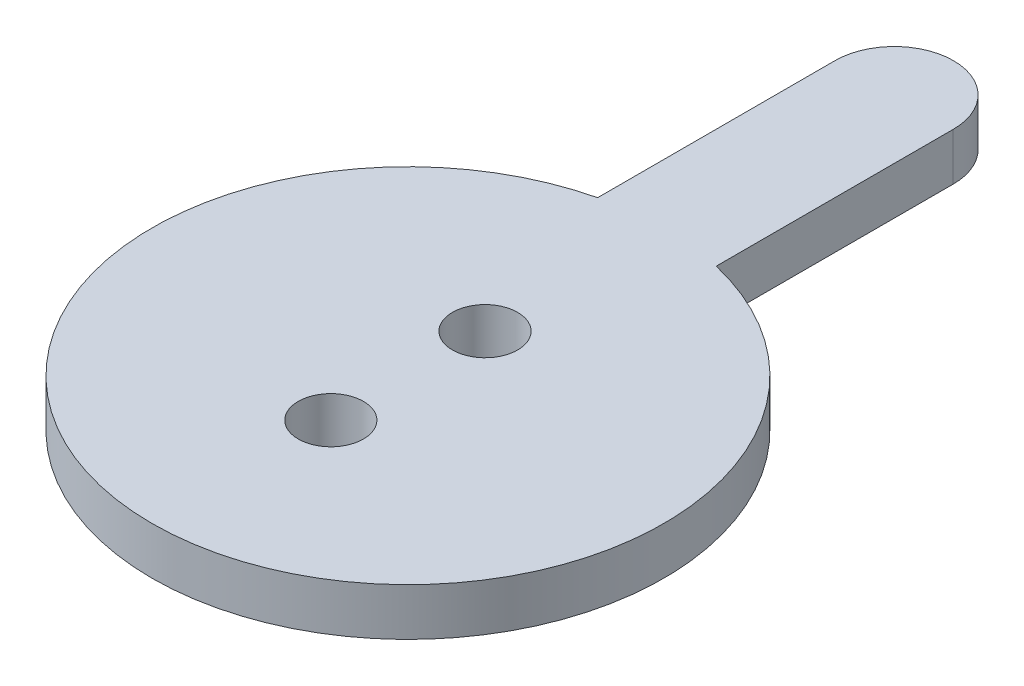
from build123d import *

# Parameters (mm, degrees)
SKETCH1_R           = 2.75
BOSS_EXTRUDE1_DEPTH = 4


with BuildPart() as part:
    # Sketch1 → Boss-Extrude1 (new body)
    with BuildSketch(Plane(origin=(0, 0, 0), x_dir=(1, 0, 0), z_dir=(0, 1, 0))):
        with BuildLine():
            Line((-5, 40.993730005), (-5, 20.993730005))
            ThreePointArc((-5, 20.993730005), (0.000189813, -21.580933703), (4.999630703, 20.993817955))
            Line((4.999630703, 20.993817955), (4.999630703, 40.938908708))
            ThreePointArc((4.999630703, 40.938908708), (0.02741127, 45.999928793), (-5, 40.993730005))
        make_face()
        with Locations((0, -6.5)):
            Circle(SKETCH1_R, mode=Mode.SUBTRACT)
        with Locations((0, 6.5)):
            Circle(SKETCH1_R, mode=Mode.SUBTRACT)
    extrude(amount=BOSS_EXTRUDE1_DEPTH)


solid = part.part
